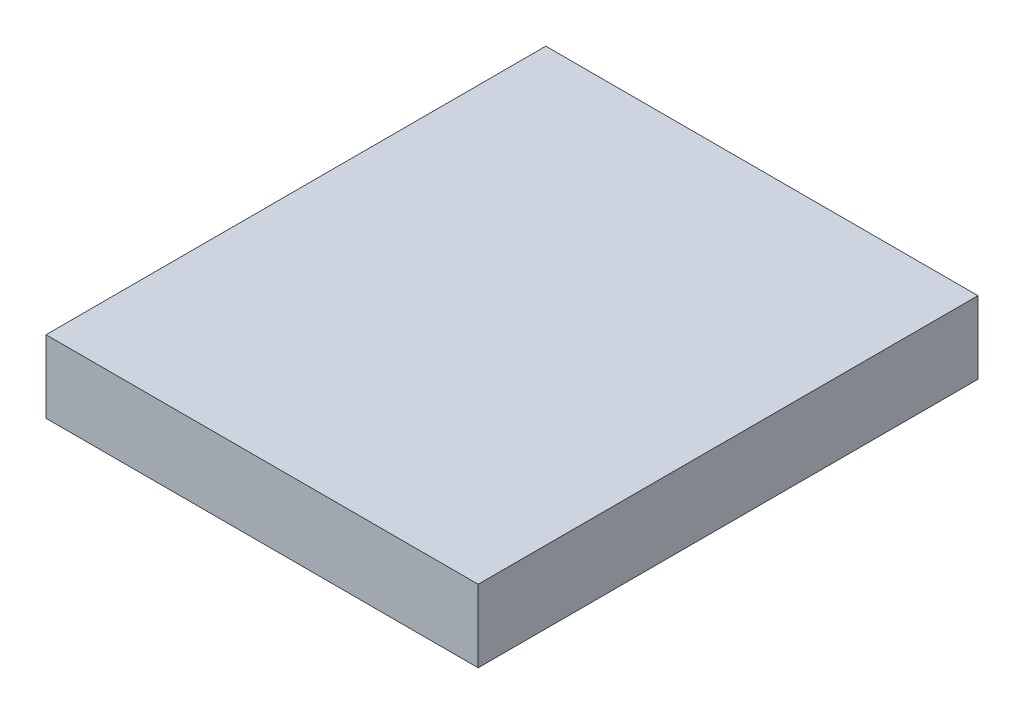
from build123d import *

# Parameters (mm, degrees)
SKETCH1_W           = 34.75
SKETCH1_H           = 40.19
BOSS_EXTRUDE1_DEPTH = 5.82


with BuildPart() as part:
    # Sketch1 → Boss-Extrude1 (new body)
    with BuildSketch(Plane(origin=(0, 0, 0), x_dir=(1, 0, 0), z_dir=(0, 1, 0))):
        with Locations((17.375, 20.095)):
            Rectangle(SKETCH1_W, SKETCH1_H)
    extrude(amount=BOSS_EXTRUDE1_DEPTH)


solid = part.part
